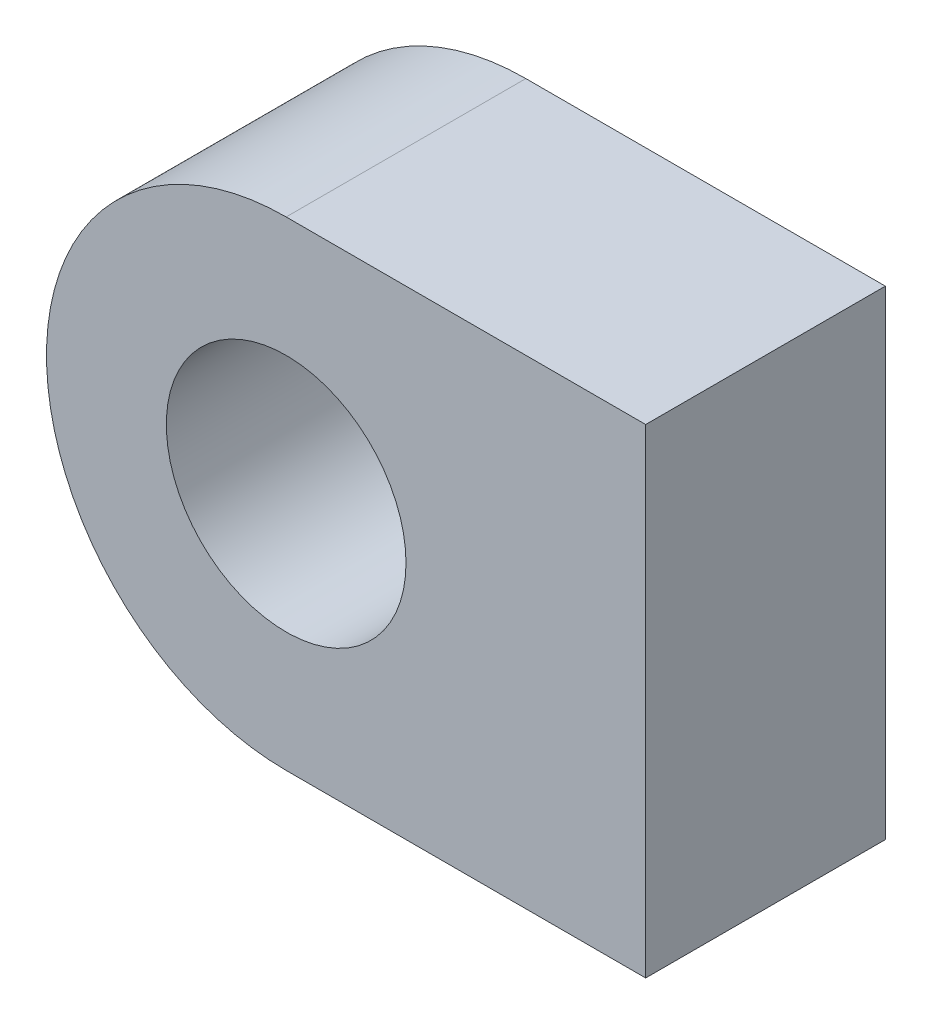
from build123d import *

# Parameters (mm, degrees)
SKETCH2_R           = 5
BOSS_EXTRUDE1_DEPTH = 10


with BuildPart() as part:
    # Sketch2 → Boss-Extrude1 (new body)
    with BuildSketch(Plane.XY):
        with BuildLine():
            Line((0, 10), (0, -10))
            Line((0, -10), (-15, -10))
            ThreePointArc((-15, -10), (-25, 0), (-15, 10))
            Line((-15, 10), (0, 10))
        make_face()
        with Locations((-15, 0)):
            Circle(SKETCH2_R, mode=Mode.SUBTRACT)
    extrude(amount=-BOSS_EXTRUDE1_DEPTH)


solid = part.part
